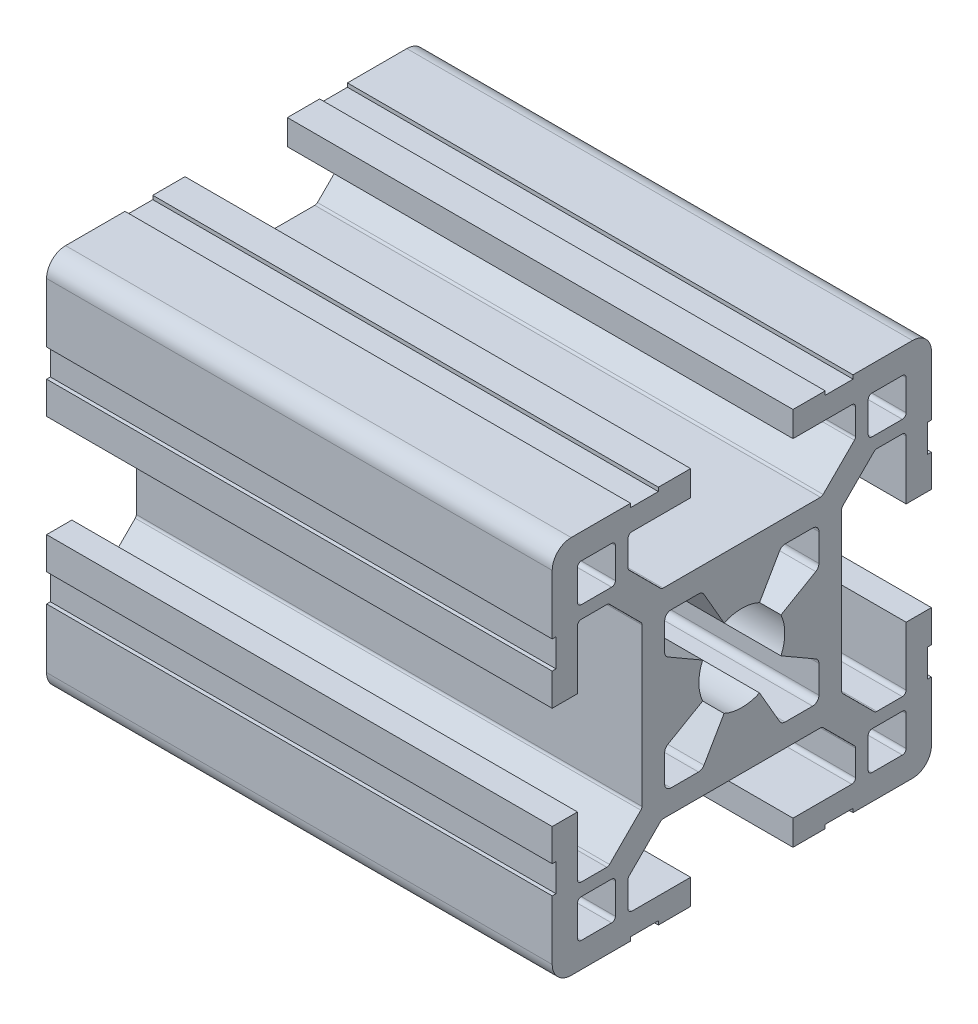
from build123d import *

# Parameters (mm, degrees)
QUADRADO_PF30_11_PERFIL_3030_CENTRO_M8_DEPTH = 40


with BuildPart() as part:
    # Sketch1 → Quadrado PF30-11 - PERFIL 3030 CENTRO M8(1) (new body)
    with BuildSketch(Plane.YZ):
        with BuildLine():
            Line((14.999995923, 6.599996803), (14.699995923, 6.599996803))
            Line((14.699995923, 6.599996803), (14.699995923, 8.799996803))
            Line((14.699995923, 8.799996803), (14.999995923, 8.799996803))
            Line((14.999995923, 8.799996803), (14.999995923, 13.499995825))
            ThreePointArc((14.999995923, 13.499995825), (14.560656066, 14.560656066), (13.499995825, 14.999995923))
            Line((13.499995825, 14.999995923), (8.799996818, 14.999995923))
            Line((8.799996818, 14.999995923), (8.799996818, 14.699995923))
            Line((8.799996818, 14.699995923), (6.599996818, 14.699995923))
            Line((6.599996818, 14.699995923), (6.599996818, 14.999995923))
            Line((6.599996818, 14.999995923), (4.0499987, 14.999995923))
            Line((4.0499987, 14.999995923), (4.0499987, 12.999995366))
            Line((4.0499987, 12.999995366), (8.699997649, 12.999995366))
            ThreePointArc((8.699997649, 12.999995366), (8.912129683, 12.9121274), (8.999997649, 12.699995366))
            Line((8.999997649, 12.699995366), (8.999997649, 10.679894006))
            ThreePointArc((8.999997649, 10.679894006), (8.977161511, 10.565088981), (8.912129691, 10.467761979))
            Line((8.912129691, 10.467761979), (6.432230191, 7.987862303))
            ThreePointArc((6.432230191, 7.987862303), (6.334903184, 7.922830472), (6.220098149, 7.89999433))
            Line((6.220098149, 7.89999433), (-6.220098149, 7.89999433))
            ThreePointArc((-6.220098149, 7.89999433), (-6.334903184, 7.922830472), (-6.432230191, 7.987862303))
            Line((-6.432230191, 7.987862303), (-8.912129691, 10.467761979))
            ThreePointArc((-8.912129691, 10.467761979), (-8.977161511, 10.565088981), (-8.999997649, 10.679894006))
            Line((-8.999997649, 10.679894006), (-8.999997649, 12.699995366))
            ThreePointArc((-8.999997649, 12.699995366), (-8.912129683, 12.9121274), (-8.699997649, 12.999995366))
            Line((-8.699997649, 12.999995366), (-4.0499987, 12.999995366))
            Line((-4.0499987, 12.999995366), (-4.0499987, 14.999995923))
            Line((-4.0499987, 14.999995923), (-6.599996818, 14.999995923))
            Line((-6.599996818, 14.999995923), (-6.599996818, 14.699995923))
            Line((-6.599996818, 14.699995923), (-8.799996818, 14.699995923))
            Line((-8.799996818, 14.699995923), (-8.799996818, 14.999995923))
            Line((-8.799996818, 14.999995923), (-13.499995825, 14.999995923))
            ThreePointArc((-13.499995825, 14.999995923), (-14.560656066, 14.560656066), (-14.999995923, 13.499995825))
            Line((-14.999995923, 13.499995825), (-14.999995923, 8.799996803))
            Line((-14.999995923, 8.799996803), (-14.699995923, 8.799996803))
            Line((-14.699995923, 8.799996803), (-14.699995923, 6.599996803))
            Line((-14.699995923, 6.599996803), (-14.999995923, 6.599996803))
            Line((-14.999995923, 6.599996803), (-14.999995923, 4.0499987))
            Line((-14.999995923, 4.0499987), (-12.999995366, 4.0499987))
            Line((-12.999995366, 4.0499987), (-12.999995366, 8.699997649))
            ThreePointArc((-12.999995366, 8.699997649), (-12.9121274, 8.912129683), (-12.699995366, 8.999997649))
            Line((-12.699995366, 8.999997649), (-10.679894006, 8.999997649))
            ThreePointArc((-10.679894006, 8.999997649), (-10.565088981, 8.977161511), (-10.467761979, 8.912129691))
            Line((-10.467761979, 8.912129691), (-7.987862303, 6.432230191))
            ThreePointArc((-7.987862303, 6.432230191), (-7.922830472, 6.334903184), (-7.89999433, 6.220098149))
            Line((-7.89999433, 6.220098149), (-7.89999433, -6.220098149))
            ThreePointArc((-7.89999433, -6.220098149), (-7.922830472, -6.334903184), (-7.987862303, -6.432230191))
            Line((-7.987862303, -6.432230191), (-10.467761979, -8.912129691))
            ThreePointArc((-10.467761979, -8.912129691), (-10.565088981, -8.977161511), (-10.679894006, -8.999997649))
            Line((-10.679894006, -8.999997649), (-12.699995366, -8.999997649))
            ThreePointArc((-12.699995366, -8.999997649), (-12.9121274, -8.912129683), (-12.999995366, -8.699997649))
            Line((-12.999995366, -8.699997649), (-12.999995366, -4.0499987))
            Line((-12.999995366, -4.0499987), (-14.999995923, -4.0499987))
            Line((-14.999995923, -4.0499987), (-14.999995923, -6.599996803))
            Line((-14.999995923, -6.599996803), (-14.699995923, -6.599996803))
            Line((-14.699995923, -6.599996803), (-14.699995923, -8.799996803))
            Line((-14.699995923, -8.799996803), (-14.999995923, -8.799996803))
            Line((-14.999995923, -8.799996803), (-14.999995923, -13.499995825))
            ThreePointArc((-14.999995923, -13.499995825), (-14.560656066, -14.560656066), (-13.499995825, -14.999995923))
            Line((-13.499995825, -14.999995923), (-8.799996818, -14.999995923))
            Line((-8.799996818, -14.999995923), (-8.799996818, -14.699995923))
            Line((-8.799996818, -14.699995923), (-6.599996818, -14.699995923))
            Line((-6.599996818, -14.699995923), (-6.599996818, -14.999995923))
            Line((-6.599996818, -14.999995923), (-4.0499987, -14.999995923))
            Line((-4.0499987, -14.999995923), (-4.0499987, -12.999995366))
            Line((-4.0499987, -12.999995366), (-8.699997649, -12.999995366))
            ThreePointArc((-8.699997649, -12.999995366), (-8.912129683, -12.9121274), (-8.999997649, -12.699995366))
            Line((-8.999997649, -12.699995366), (-8.999997649, -10.679894006))
            ThreePointArc((-8.999997649, -10.679894006), (-8.977161511, -10.565088981), (-8.912129691, -10.467761979))
            Line((-8.912129691, -10.467761979), (-6.432230191, -7.987862303))
            ThreePointArc((-6.432230191, -7.987862303), (-6.334903184, -7.922830472), (-6.220098149, -7.89999433))
            Line((-6.220098149, -7.89999433), (6.220098149, -7.89999433))
            ThreePointArc((6.220098149, -7.89999433), (6.334903184, -7.922830472), (6.432230191, -7.987862303))
            Line((6.432230191, -7.987862303), (8.912129691, -10.467761979))
            ThreePointArc((8.912129691, -10.467761979), (8.977161511, -10.565088981), (8.999997649, -10.679894006))
            Line((8.999997649, -10.679894006), (8.999997649, -12.699995366))
            ThreePointArc((8.999997649, -12.699995366), (8.912129683, -12.9121274), (8.699997649, -12.999995366))
            Line((8.699997649, -12.999995366), (4.0499987, -12.999995366))
            Line((4.0499987, -12.999995366), (4.0499987, -14.999995923))
            Line((4.0499987, -14.999995923), (6.599996818, -14.999995923))
            Line((6.599996818, -14.999995923), (6.599996818, -14.699995923))
            Line((6.599996818, -14.699995923), (8.799996818, -14.699995923))
            Line((8.799996818, -14.699995923), (8.799996818, -14.999995923))
            Line((8.799996818, -14.999995923), (13.499995825, -14.999995923))
            ThreePointArc((13.499995825, -14.999995923), (14.560656066, -14.560656066), (14.999995923, -13.499995825))
            Line((14.999995923, -13.499995825), (14.999995923, -8.799996803))
            Line((14.999995923, -8.799996803), (14.699995923, -8.799996803))
            Line((14.699995923, -8.799996803), (14.699995923, -6.599996803))
            Line((14.699995923, -6.599996803), (14.999995923, -6.599996803))
            Line((14.999995923, -6.599996803), (14.999995923, -4.0499987))
            Line((14.999995923, -4.0499987), (12.999995366, -4.0499987))
            Line((12.999995366, -4.0499987), (12.999995366, -8.699997649))
            ThreePointArc((12.999995366, -8.699997649), (12.9121274, -8.912129683), (12.699995366, -8.999997649))
            Line((12.699995366, -8.999997649), (10.679894006, -8.999997649))
            ThreePointArc((10.679894006, -8.999997649), (10.565088981, -8.977161511), (10.467761979, -8.912129691))
            Line((10.467761979, -8.912129691), (7.987862303, -6.432230191))
            ThreePointArc((7.987862303, -6.432230191), (7.922830472, -6.334903184), (7.89999433, -6.220098149))
            Line((7.89999433, -6.220098149), (7.89999433, 6.220098149))
            ThreePointArc((7.89999433, 6.220098149), (7.922830472, 6.334903184), (7.987862303, 6.432230191))
            Line((7.987862303, 6.432230191), (10.467761979, 8.912129691))
            ThreePointArc((10.467761979, 8.912129691), (10.565088981, 8.977161511), (10.679894006, 8.999997649))
            Line((10.679894006, 8.999997649), (12.699995366, 8.999997649))
            ThreePointArc((12.699995366, 8.999997649), (12.9121274, 8.912129683), (12.999995366, 8.699997649))
            Line((12.999995366, 8.699997649), (12.999995366, 4.0499987))
            Line((12.999995366, 4.0499987), (14.999995923, 4.0499987))
            Line((14.999995923, 4.0499987), (14.999995923, 6.599996803))
        make_face()
        with BuildLine():
            Line((-6.1, -3.425408784), (-6.1, -5.6))
            ThreePointArc((-6.1, -5.6), (-5.953553391, -5.953553391), (-5.6, -6.1))
            Line((-5.6, -6.1), (-3.425408784, -6.1))
            ThreePointArc((-3.425408784, -6.1), (-3.175408784, -6.033012702), (-2.992396082, -5.85))
            Line((-2.992396082, -5.85), (-1.402974441, -3.097040962))
            ThreePointArc((-1.402974441, -3.097040962), (0, -3.4), (1.402974441, -3.097040962))
            Line((1.402974441, -3.097040962), (2.992396082, -5.85))
            ThreePointArc((2.992396082, -5.85), (3.175408784, -6.033012702), (3.425408784, -6.1))
            Line((3.425408784, -6.1), (5.6, -6.1))
            ThreePointArc((5.6, -6.1), (5.953553391, -5.953553391), (6.1, -5.6))
            Line((6.1, -5.6), (6.1, -3.425408784))
            ThreePointArc((6.1, -3.425408784), (6.033012702, -3.175408784), (5.85, -2.992396082))
            Line((5.85, -2.992396082), (3.097040962, -1.402974441))
            ThreePointArc((3.097040962, -1.402974441), (3.4, 0), (3.097040962, 1.402974441))
            Line((3.097040962, 1.402974441), (5.85, 2.992396082))
            ThreePointArc((5.85, 2.992396082), (6.033012702, 3.175408784), (6.1, 3.425408784))
            Line((6.1, 3.425408784), (6.1, 5.6))
            ThreePointArc((6.1, 5.6), (5.953553391, 5.953553391), (5.6, 6.1))
            Line((5.6, 6.1), (3.425408784, 6.1))
            ThreePointArc((3.425408784, 6.1), (3.175408784, 6.033012702), (2.992396082, 5.85))
            Line((2.992396082, 5.85), (1.402974441, 3.097040962))
            ThreePointArc((1.402974441, 3.097040962), (0, 3.4), (-1.402974441, 3.097040962))
            Line((-1.402974441, 3.097040962), (-2.992396082, 5.85))
            ThreePointArc((-2.992396082, 5.85), (-3.175408784, 6.033012702), (-3.425408784, 6.1))
            Line((-3.425408784, 6.1), (-5.6, 6.1))
            ThreePointArc((-5.6, 6.1), (-5.953553391, 5.953553391), (-6.1, 5.6))
            Line((-6.1, 5.6), (-6.1, 3.425408784))
            ThreePointArc((-6.1, 3.425408784), (-6.033012702, 3.175408784), (-5.85, 2.992396082))
            Line((-5.85, 2.992396082), (-3.097040962, 1.402974441))
            ThreePointArc((-3.097040962, 1.402974441), (-3.4, 0), (-3.097040962, -1.402974441))
            Line((-3.097040962, -1.402974441), (-5.85, -2.992396082))
            ThreePointArc((-5.85, -2.992396082), (-6.033012702, -3.175408784), (-6.1, -3.425408784))
        make_face(mode=Mode.SUBTRACT)
        with BuildLine():
            Line((9.999995366, 12.699997649), (9.999995366, 10.299997649))
            ThreePointArc((9.999995366, 10.299997649), (10.087863331, 10.087865615), (10.299995366, 9.999997649))
            Line((10.299995366, 9.999997649), (12.699995366, 9.999997649))
            ThreePointArc((12.699995366, 9.999997649), (12.9121274, 10.087865615), (12.999995366, 10.299997649))
            Line((12.999995366, 10.299997649), (12.999995366, 12.699997649))
            ThreePointArc((12.999995366, 12.699997649), (12.9121274, 12.912129683), (12.699995366, 12.999997649))
            Line((12.699995366, 12.999997649), (10.299995366, 12.999997649))
            ThreePointArc((10.299995366, 12.999997649), (10.087863331, 12.912129683), (9.999995366, 12.699997649))
        make_face(mode=Mode.SUBTRACT)
        with BuildLine():
            Line((12.999995366, -12.699997649), (12.999995366, -10.299997649))
            ThreePointArc((12.999995366, -10.299997649), (12.9121274, -10.087865615), (12.699995366, -9.999997649))
            Line((12.699995366, -9.999997649), (10.299995366, -9.999997649))
            ThreePointArc((10.299995366, -9.999997649), (10.087863331, -10.087865615), (9.999995366, -10.299997649))
            Line((9.999995366, -10.299997649), (9.999995366, -12.699997649))
            ThreePointArc((9.999995366, -12.699997649), (10.087863331, -12.912129683), (10.299995366, -12.999997649))
            Line((10.299995366, -12.999997649), (12.699995366, -12.999997649))
            ThreePointArc((12.699995366, -12.999997649), (12.9121274, -12.912129683), (12.999995366, -12.699997649))
        make_face(mode=Mode.SUBTRACT)
        with BuildLine():
            Line((-10.299995366, -9.999997649), (-12.699995366, -9.999997649))
            ThreePointArc((-12.699995366, -9.999997649), (-12.9121274, -10.087865615), (-12.999995366, -10.299997649))
            Line((-12.999995366, -10.299997649), (-12.999995366, -12.699997649))
            ThreePointArc((-12.999995366, -12.699997649), (-12.9121274, -12.912129683), (-12.699995366, -12.999997649))
            Line((-12.699995366, -12.999997649), (-10.299995366, -12.999997649))
            ThreePointArc((-10.299995366, -12.999997649), (-10.087863331, -12.912129683), (-9.999995366, -12.699997649))
            Line((-9.999995366, -12.699997649), (-9.999995366, -10.299997649))
            ThreePointArc((-9.999995366, -10.299997649), (-10.087863331, -10.087865615), (-10.299995366, -9.999997649))
        make_face(mode=Mode.SUBTRACT)
        with BuildLine():
            Line((-12.999995366, 12.699997649), (-12.999995366, 10.299997649))
            ThreePointArc((-12.999995366, 10.299997649), (-12.9121274, 10.087865615), (-12.699995366, 9.999997649))
            Line((-12.699995366, 9.999997649), (-10.299995366, 9.999997649))
            ThreePointArc((-10.299995366, 9.999997649), (-10.087863331, 10.087865615), (-9.999995366, 10.299997649))
            Line((-9.999995366, 10.299997649), (-9.999995366, 12.699997649))
            ThreePointArc((-9.999995366, 12.699997649), (-10.087863331, 12.912129683), (-10.299995366, 12.999997649))
            Line((-10.299995366, 12.999997649), (-12.699995366, 12.999997649))
            ThreePointArc((-12.699995366, 12.999997649), (-12.9121274, 12.912129683), (-12.999995366, 12.699997649))
        make_face(mode=Mode.SUBTRACT)
    extrude(amount=QUADRADO_PF30_11_PERFIL_3030_CENTRO_M8_DEPTH)


solid = part.part
